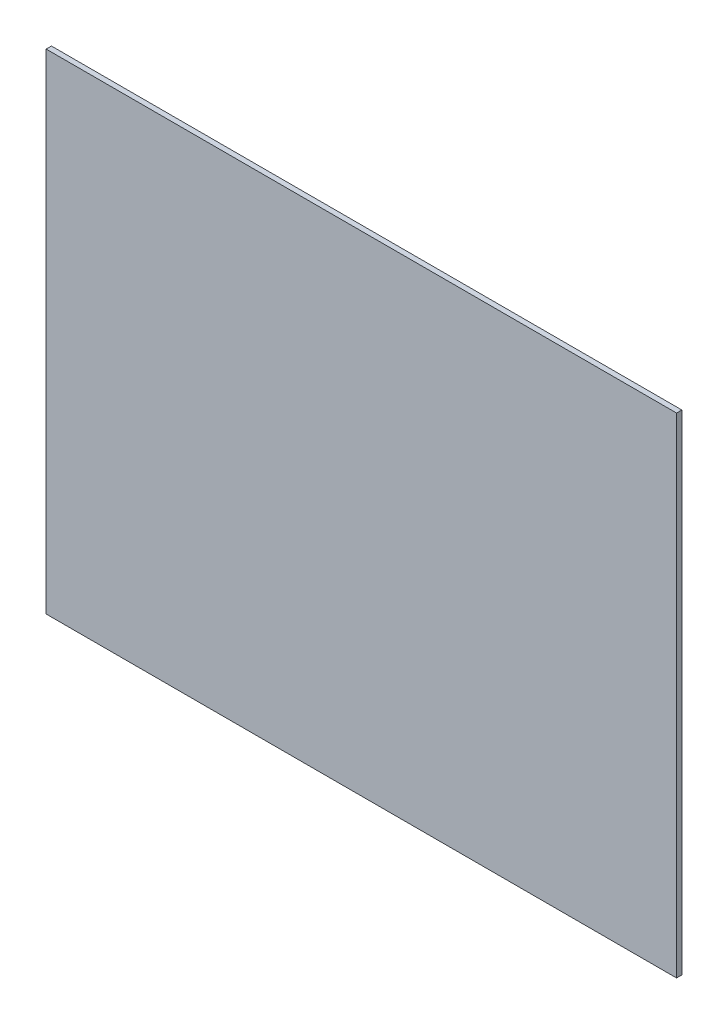
from build123d import *

# Parameters (mm, degrees)
SKETCH1_W           = 536
SKETCH1_H           = 416
BOSS_EXTRUDE1_DEPTH = 2.2479


with BuildPart() as part:
    # Sketch1 → Boss-Extrude1 (new body, symmetric)
    with BuildSketch(Plane.XY):
        Rectangle(SKETCH1_W, SKETCH1_H)
    extrude(amount=BOSS_EXTRUDE1_DEPTH, both=True)


solid = part.part
